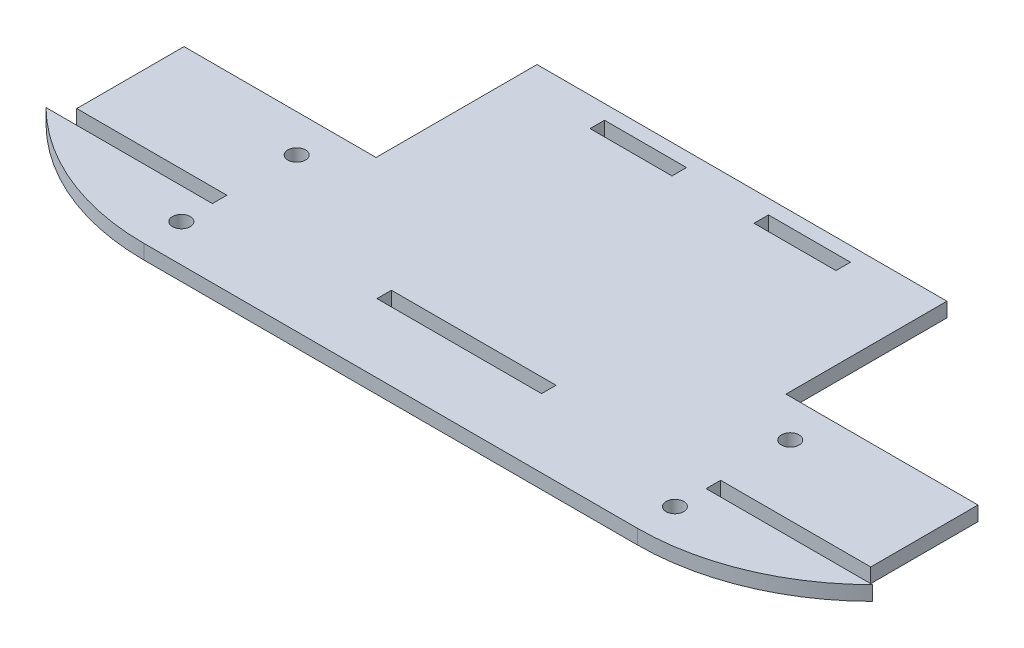
from build123d import *

# Parameters (mm, degrees)
SKETCH1_R           = 1.65
SKETCH1_W           = 30.68
SKETCH1_H           = 2.7
SKETCH1_W_2         = 15.28
BOSS_EXTRUDE1_DEPTH = 2.7


with BuildPart() as part:
    # Sketch1 → Boss-Extrude1 (new body)
    with BuildSketch(Plane(origin=(0, 0, 0), x_dir=(1, 0, 0), z_dir=(0, 1, 0))):
        with BuildLine():
            Line((-46, 0), (46, 0))
            ThreePointArc((46, 0), (62.780941571, 3.32568378), (77.025151087, 12.8))
            Line((77.025151087, 12.8), (46.015151087, 12.8))
            Line((46.015151087, 12.8), (46.015151087, 15.5))
            Line((46.015151087, 15.5), (73.995151087, 15.5))
            Line((73.995151087, 15.5), (73.995151087, 35.5))
            Line((73.995151087, 35.5), (38.2, 35.5))
            Line((38.2, 35.5), (38.2, 65.5))
            Line((38.2, 65.5), (-38.2, 65.5))
            Line((-38.2, 65.5), (-38.2, 35.5))
            Line((-38.2, 35.5), (-73.995151087, 35.5))
            Line((-73.995151087, 35.5), (-73.995151087, 15.5))
            Line((-73.995151087, 15.5), (-46.015151087, 15.5))
            Line((-46.015151087, 15.5), (-46.015151087, 12.8))
            Line((-46.015151087, 12.8), (-77.025151087, 12.8))
            ThreePointArc((-77.025151087, 12.8), (-62.780941571, 3.32568378), (-46, 0))
        make_face()
        with Locations((46, 28.5)):
            Circle(SKETCH1_R, mode=Mode.SUBTRACT)
        with Locations((46, 7)):
            Circle(SKETCH1_R, mode=Mode.SUBTRACT)
        with Locations((-46, 7)):
            Circle(SKETCH1_R, mode=Mode.SUBTRACT)
        with Locations((-46, 28.5)):
            Circle(SKETCH1_R, mode=Mode.SUBTRACT)
        with Locations((0, 14.15)):
            Rectangle(SKETCH1_W, SKETCH1_H, mode=Mode.SUBTRACT)
        with Locations((-15.28, 61.45)):
            Rectangle(SKETCH1_W_2, SKETCH1_H, mode=Mode.SUBTRACT)
        with Locations((15.28, 61.45)):
            Rectangle(SKETCH1_W_2, SKETCH1_H, mode=Mode.SUBTRACT)
    extrude(amount=BOSS_EXTRUDE1_DEPTH)


solid = part.part
